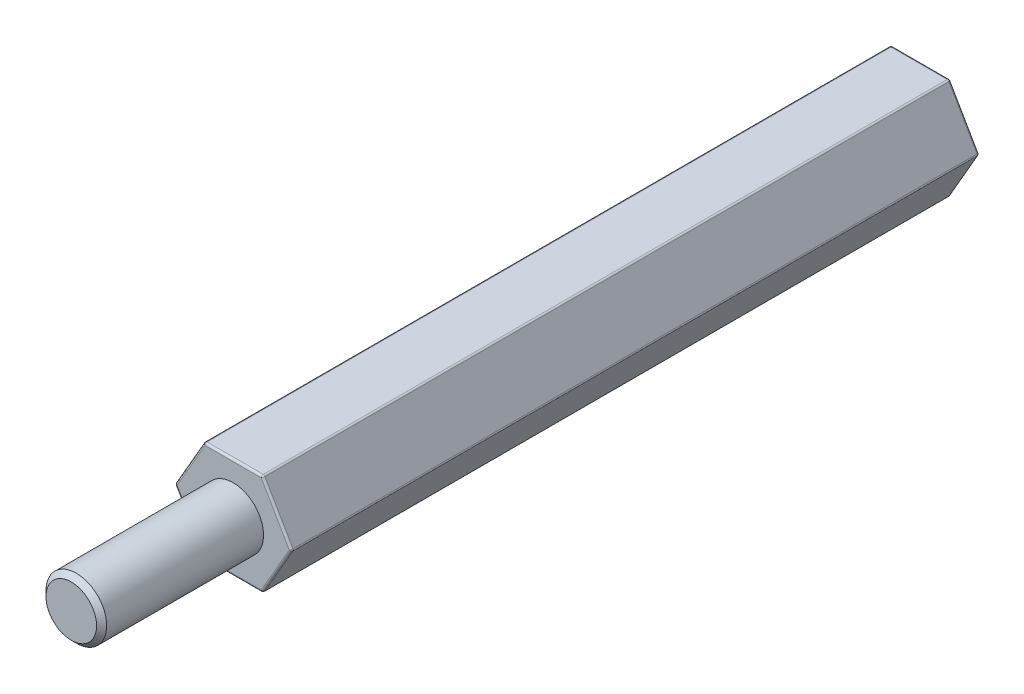
from build123d import *

# Parameters (mm, degrees)
SKETCH_1_R      = 1.5
EXTRUDE_1_DEPTH = 8
EXTRUDE_3_DEPTH = 34
M3X0_51_D       = 2.5
M3X0_51_DEPTH   = 4.3
M3X0_51_TIP     = 0.751075774
CHAMFER_1_SIZE  = 0.25
FILLET_1_R      = 0.1


with BuildPart() as part:
    # Эскиз1 → Бобышка-Вытянуть1 (new body)
    with BuildSketch(Plane.XY):
        Circle(SKETCH_1_R)
    extrude(amount=EXTRUDE_1_DEPTH)

    # Эскиз3 → Бобышка-Вытянуть3 (add)
    with BuildSketch(Plane(origin=(0, 0, 0), x_dir=(-1, 0, 0), z_dir=(0, 0, -1))):
        Polygon((2.886751346, 0), (1.443375673, 2.5), (-1.443375673, 2.5), (-2.886751346, 0), (-1.443375673, -2.5), (1.443375673, -2.5), align=None)
    extrude(amount=EXTRUDE_3_DEPTH)

    # Сверление под метчик M3x0.51
    with Locations(Plane(origin=(0, 0, -34), x_dir=(-1, 0, 0), z_dir=(0, 0, -1))):
        with Locations((0, 0)):
            Hole(M3X0_51_D / 2, depth=M3X0_51_DEPTH)
            with Locations((0, 0, -(M3X0_51_DEPTH + M3X0_51_TIP / 2))):  # 118° drill point
                Cone(0, M3X0_51_D / 2, M3X0_51_TIP, mode=Mode.SUBTRACT)

    # Фаска1
    chamfer_1_edges = [part.edges().sort_by_distance(p)[0] for p in [
        (-1.25, 0, -34),
        (-1.5, 0, 8),
    ]]
    chamfer(chamfer_1_edges, length=CHAMFER_1_SIZE)

    # Скругление1
    fillet_1_edges = [part.edges().sort_by_distance(p)[0] for p in [
        (-2.165063509, -1.25, 0),
        (-1.443375673, -2.5, -17),
        (-2.165063509, 1.25, 0),
        (-2.886751346, 0, -17),
        (0, 2.5, 0),
        (-1.443375673, 2.5, -17),
        (2.165063509, 1.25, 0),
        (1.443375673, 2.5, -17),
        (2.165063509, -1.25, 0),
        (2.886751346, 0, -17),
        (0, -2.5, 0),
        (1.443375673, -2.5, -17),
        (-2.165063509, -1.25, -34),
        (-2.165063509, 1.25, -34),
        (0, 2.5, -34),
        (2.165063509, 1.25, -34),
        (2.165063509, -1.25, -34),
        (0, -2.5, -34),
    ]]
    fillet(fillet_1_edges, radius=FILLET_1_R)


solid = part.part
